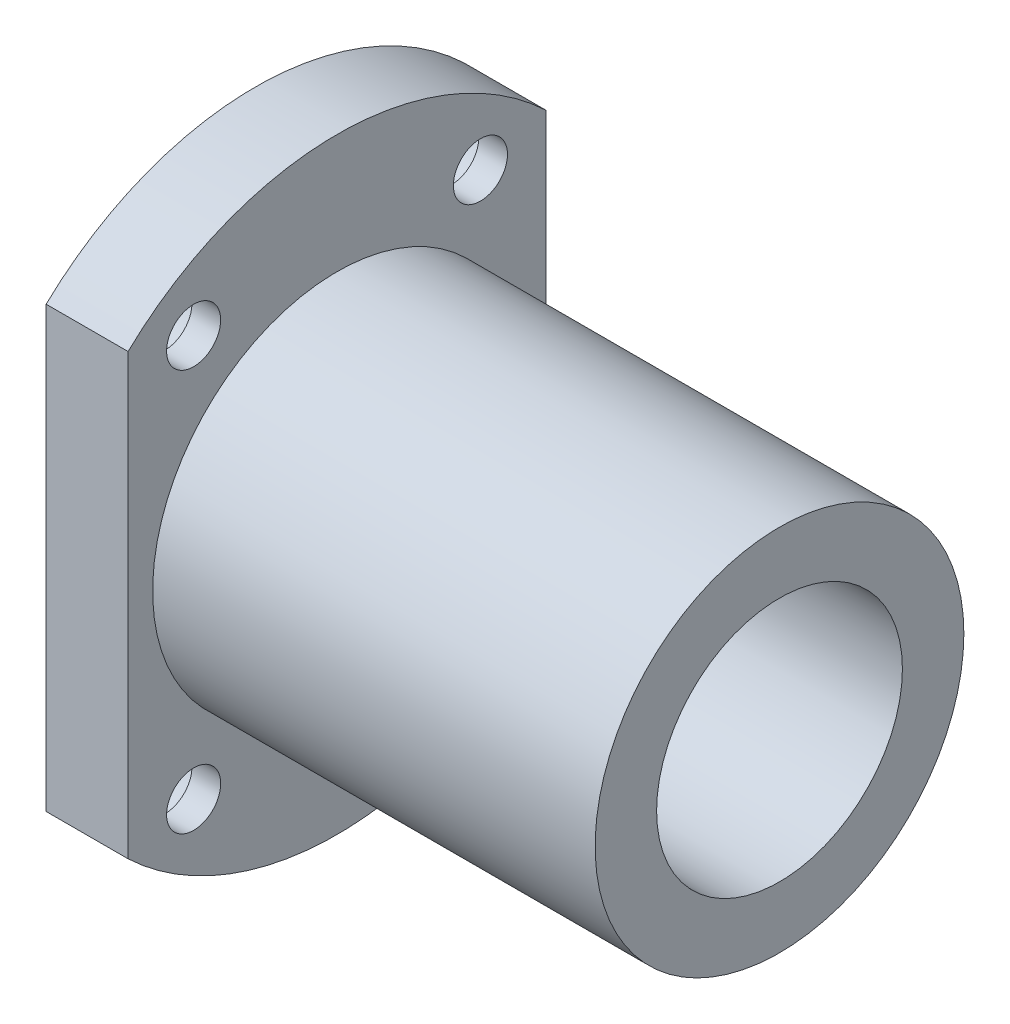
from build123d import *

# Parameters (mm, degrees)
SKETCH_1_R                   = 37
EXTRUDE_1_DEPTH              = 10
SKETCH_2_R                   = 22.5
EXTRUDE_2_DEPTH              = 54
SKETCH_3_R                   = 15
CUT_EXTRUDE_1_DEPTH          = 65
CUT_EXTRUDE_2_DEPTH          = 65
HOLE_WIZARD_M6_2_D           = 6.6
HOLE_WIZARD_M6_2_CBORE_D     = 11
HOLE_WIZARD_M6_2_CBORE_DEPTH = 6.5


with BuildPart() as part:
    # 草图1 → 凸台-拉伸1 (new body)
    with BuildSketch(Plane(origin=(0, 0, 0), x_dir=(0, 0, -1), z_dir=(1, 0, 0))):
        Circle(SKETCH_1_R)
    extrude(amount=EXTRUDE_1_DEPTH)

    # 草图2 → 凸台-拉伸2 (add)
    with BuildSketch(Plane(origin=(10, 0, 0), x_dir=(0, 0, -1), z_dir=(1, 0, 0))):
        Circle(SKETCH_2_R)
    extrude(amount=EXTRUDE_2_DEPTH)

    # 草图3 → 切除-拉伸1 (cut, through all)
    with BuildSketch(Plane.ZY):
        Circle(SKETCH_3_R)
    extrude(amount=-CUT_EXTRUDE_1_DEPTH, mode=Mode.SUBTRACT)

    # 草图6 → 切除-拉伸2 (cut, through all)
    with BuildSketch(Plane.ZY):
        with BuildLine():
            Line((-25.5, 26.809513237), (-25.5, -26.809513237))
            ThreePointArc((-25.5, -26.809513237), (-37, 0), (-25.5, 26.809513237))
        make_face()
        with BuildLine():
            Line((25.5, 26.809513237), (25.5, -26.809513237))
            ThreePointArc((25.5, -26.809513237), (37, 0), (25.5, 26.809513237))
        make_face()
    extrude(amount=-CUT_EXTRUDE_2_DEPTH, mode=Mode.SUBTRACT)

    # M6 六角头螺栓的柱形沉头孔2 (through all)
    with Locations(Plane.ZY):
        with Locations((-17.5, 24.5), (17.5, 24.5), (17.5, -24.5), (-17.5, -24.5)):
            CounterBoreHole(HOLE_WIZARD_M6_2_D / 2, HOLE_WIZARD_M6_2_CBORE_D / 2, HOLE_WIZARD_M6_2_CBORE_DEPTH)


solid = part.part
